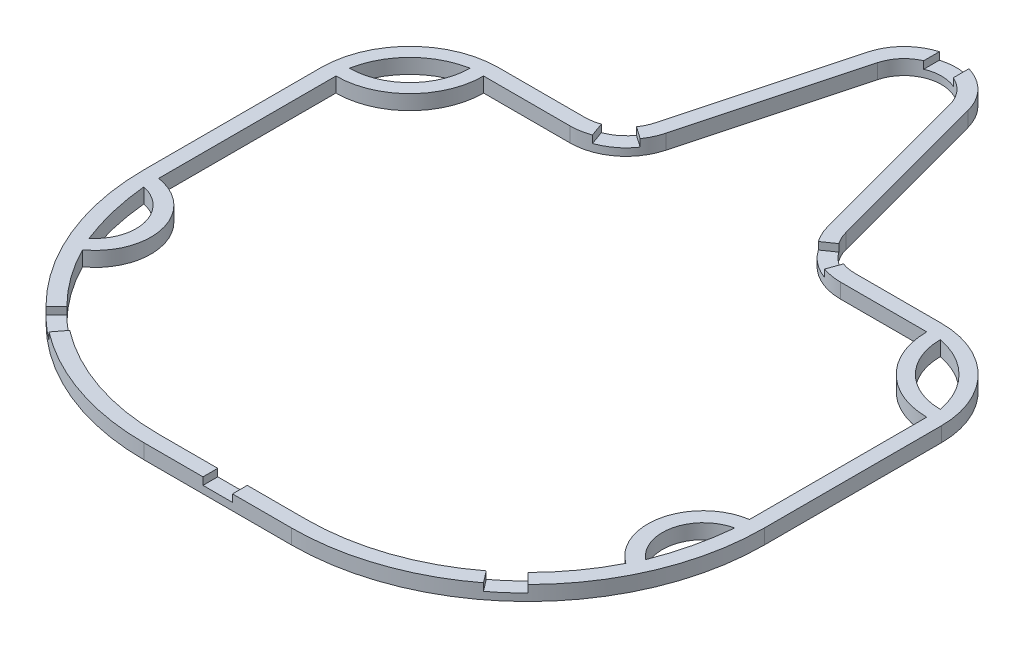
from build123d import *

# Parameters (mm, degrees)
BOSS_EXTRUDE1_DEPTH = 1.25
BOSS_EXTRUDE5_DEPTH = 2.5
SKETCH6_W           = 5
SKETCH6_H           = 4
CUT_EXTRUDE1_DEPTH  = 1.25
CUT_EXTRUDE2_DEPTH  = 2.5


with BuildPart() as part:
    # Sketch2 → Boss-Extrude1 (new body, symmetric)
    with BuildSketch(Plane(origin=(0, 0, 0), x_dir=(1, 0, 0), z_dir=(0, 1, 0))):
        with BuildLine():
            Line((-16.109808132, 35.188266684), (-8.537351427, 63.449059844))
            ThreePointArc((-8.537351427, 63.449059844), (0, 70), (8.537351427, 63.449059844))
            Line((8.537351427, 63.449059844), (16.109808132, 35.188266684))
            ThreePointArc((16.109808132, 35.188266684), (18.609958913, 31.446526618), (22.871288916, 30))
            Line((22.871288916, 30), (37.5, 30))
            ThreePointArc((37.5, 30), (48.106601718, 25.606601718), (52.5, 15))
            Line((52.5, 15), (52.5, -15))
            ThreePointArc((52.5, -15), (40.784271247, -43.284271247), (12.5, -55))
            Line((12.5, -55), (-12.5, -55))
            ThreePointArc((-12.5, -55), (-40.784271247, -43.284271247), (-52.5, -15))
            Line((-52.5, -15), (-52.5, 15))
            ThreePointArc((-52.5, 15), (-48.106601718, 25.606601718), (-37.5, 30))
            Line((-37.5, 30), (-22.871288916, 30))
            ThreePointArc((-22.871288916, 30), (-18.609958913, 31.446526618), (-16.109808132, 35.188266684))
        make_face()
        with BuildLine():
            Line((6.122536861, 62.802012231), (13.694993566, 34.541219072))
            ThreePointArc((13.694993566, 34.541219072), (17.08805534, 29.463143267), (22.871288916, 27.5))
            Line((22.871288916, 27.5), (37.5, 27.5))
            ThreePointArc((37.5, 27.5), (46.338834765, 23.838834765), (50, 15))
            Line((50, 15), (50, -15))
            ThreePointArc((50, -15), (39.016504294, -41.516504294), (12.5, -52.5))
            Line((12.5, -52.5), (-12.5, -52.5))
            ThreePointArc((-12.5, -52.5), (-39.016504294, -41.516504294), (-50, -15))
            Line((-50, -15), (-50, 15))
            ThreePointArc((-50, 15), (-46.338834765, 23.838834765), (-37.5, 27.5))
            Line((-37.5, 27.5), (-22.871288916, 27.5))
            ThreePointArc((-22.871288916, 27.5), (-17.08805534, 29.463143267), (-13.694993566, 34.541219072))
            Line((-13.694993566, 34.541219072), (-6.122536861, 62.802012231))
            ThreePointArc((-6.122536861, 62.802012231), (0, 67.5), (6.122536861, 62.802012231))
        make_face(mode=Mode.SUBTRACT)
    extrude(amount=BOSS_EXTRUDE1_DEPTH, both=True)

    # Sketch5 → Boss-Extrude5 (add)
    with BuildSketch(Plane(origin=(0, 1.25, 0), x_dir=(1, 0, 0), z_dir=(0, 1, 0))):
        with BuildLine():
            ThreePointArc((-50, 15), (-41.161165235, 18.661165235), (-37.5, 27.5))
            ThreePointArc((-37.5, 27.5), (-46.338834765, 23.838834765), (-50, 15))
        make_face()
        with BuildLine():
            ThreePointArc((37.5, 27.5), (41.161165235, 18.661165235), (50, 15))
            ThreePointArc((50, 15), (46.338834765, 23.838834765), (37.5, 27.5))
        make_face()
        with BuildLine():
            ThreePointArc((-50, -15), (-42.291585286, -22.095919329), (-45.973512014, -31.904851181))
            ThreePointArc((-45.973512014, -31.904851181), (-48.979492188, -23.688880811), (-50, -15))
        make_face()
        with BuildLine():
            ThreePointArc((50, -15), (42.291585286, -22.095919329), (45.973512014, -31.904851181))
            ThreePointArc((45.973512014, -31.904851181), (48.979492187, -23.688880811), (50, -15))
        make_face()
    extrude(amount=-BOSS_EXTRUDE5_DEPTH)

    # Sketch6 → Cut-Extrude1 (cut)
    with BuildSketch(Plane(origin=(0, 1.25, 0), x_dir=(1, 0, 0), z_dir=(0, 1, 0))):
        with Locations((0, 68.75)):
            Rectangle(SKETCH6_W, SKETCH6_H)
        with BuildLine():
            Line((-20.493193447, 30.416333701), (-19.643873637, 28.065024308))
            ThreePointArc((-19.643873637, 28.065024308), (-17.08805534, 29.463143267), (-15.076081678, 31.570014354))
            Line((-15.076081678, 31.570014354), (-17.127452004, 32.998957945))
            ThreePointArc((-17.127452004, 32.998957945), (-18.609958913, 31.446526618), (-20.493193447, 30.416333701))
        make_face()
        with BuildLine():
            Line((20.493193447, 30.416333701), (19.643873637, 28.065024308))
            ThreePointArc((19.643873637, 28.065024308), (17.08805534, 29.463143267), (15.076081678, 31.570014354))
            Line((15.076081678, 31.570014354), (17.127452004, 32.998957945))
            ThreePointArc((17.127452004, 32.998957945), (18.609958913, 31.446526618), (20.493193447, 30.416333701))
        make_face()
        with BuildLine():
            Line((-40.784271247, -43.284271247), (-39.016504294, -41.516504294))
            ThreePointArc((-39.016504294, -41.516504294), (-37.189746158, -43.225280064), (-35.253133619, -44.808470449))
            Line((-35.253133619, -44.808470449), (-36.770009194, -46.795701812))
            ThreePointArc((-36.770009194, -46.795701812), (-38.835729235, -45.106965401), (-40.784271247, -43.284271247))
        make_face()
        with BuildLine():
            Line((36.770009194, -46.795701812), (35.253133619, -44.808470449))
            ThreePointArc((35.253133619, -44.808470449), (37.189746158, -43.225280064), (39.016504294, -41.516504294))
            Line((39.016504294, -41.516504294), (40.784271247, -43.284271247))
            ThreePointArc((40.784271247, -43.284271247), (38.835729235, -45.106965401), (36.770009194, -46.795701812))
        make_face()
        with Locations((0, -54)):
            Rectangle(SKETCH6_W, SKETCH6_H)
    extrude(amount=-CUT_EXTRUDE1_DEPTH, mode=Mode.SUBTRACT)

    # Sketch7 → Cut-Extrude2 (cut)
    with BuildSketch(Plane(origin=(0, 1.25, 0), x_dir=(1, 0, 0), z_dir=(0, 1, 0))):
        with BuildLine():
            ThreePointArc((-50, 17.291666667), (-42.781618275, 20.281618275), (-39.791666667, 27.5))
            ThreePointArc((-39.791666667, 27.5), (-46.486148678, 23.986148678), (-50, 17.291666667))
        make_face()
        with BuildLine():
            ThreePointArc((39.791666667, 27.5), (46.486148678, 23.986148678), (50, 17.291666667))
            ThreePointArc((50, 17.291666667), (42.781618275, 20.281618275), (39.791666667, 27.5))
        make_face()
        with BuildLine():
            ThreePointArc((-47.100502093, -29.673283714), (-44.723551432, -22.675178049), (-50, -17.5))
            ThreePointArc((-50, -17.5), (-48.979492187, -23.688880811), (-47.100502093, -29.673283714))
        make_face()
        with BuildLine():
            ThreePointArc((50, -17.5), (48.979492187, -23.688880811), (47.100502093, -29.673283714))
            ThreePointArc((47.100502093, -29.673283714), (44.723551432, -22.675178049), (50, -17.5))
        make_face()
    extrude(amount=-CUT_EXTRUDE2_DEPTH, mode=Mode.SUBTRACT)


solid = part.part
